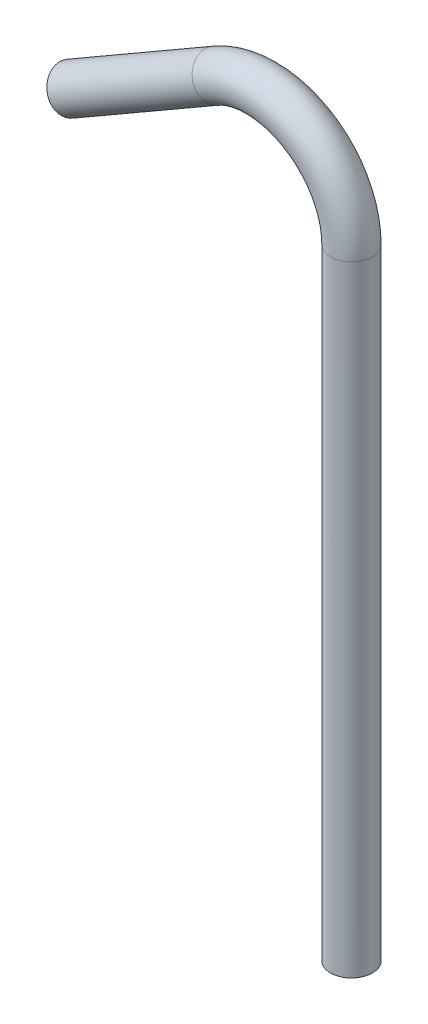
from build123d import *

# Parameters (mm, degrees)
SKETCH1_R   = 3.175
SKETCH1_R_2 = 2.16


with BuildPart() as part:
    # Sweep1: sweep along a path in Sketch2
    with BuildLine(Plane.XY) as sweep1_path:
        Line((-42.571045256, 93.062008577), (-20.574, 105.762008577))
        ThreePointArc((-20.574, 105.762008577), (-6.858, 105.762008577), (0, 93.883604139))
        Line((0, 93.883604139), (0, 0))
    # Sketch1 → Sweep1 (sweep)
    with BuildSketch(Plane(origin=(0, 0, 0), x_dir=(1, 0, 0), z_dir=(0, 1, 0))):
        Circle(SKETCH1_R)
        Circle(SKETCH1_R_2, mode=Mode.SUBTRACT)
    sweep(path=sweep1_path.line)


solid = part.part
